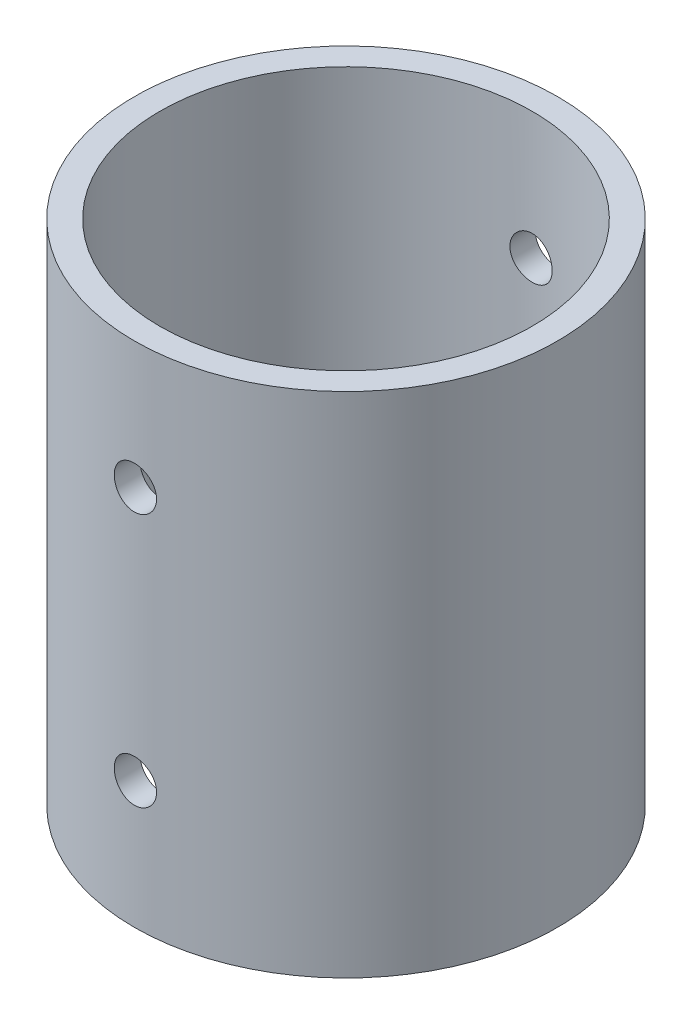
from build123d import *

# Parameters (mm, degrees)
ESBO_O1_R                = 25
ESBO_O1_R_2              = 22
RESSALTO_EXTRUS_O1_DEPTH = 60
ESBO_O2_R                = 2.5
CORTE_EXTRUS_O1_DEPTH    = 70.641941386


with BuildPart() as part:
    # Esboço1 → Ressalto-extrusão1 (new body)
    with BuildSketch(Plane(origin=(0, 0, 0), x_dir=(1, 0, 0), z_dir=(0, 1, 0))):
        with Locations(Location((0, 0, 0), (0, 0, 270))):
            Circle(ESBO_O1_R)
        with Locations(Location((0, 0, 0), (0, 0, 270))):
            Circle(ESBO_O1_R_2, mode=Mode.SUBTRACT)
    extrude(amount=RESSALTO_EXTRUS_O1_DEPTH)

    # Esboço2 → Corte-extrusão1 (cut, symmetric)
    with BuildSketch(Plane.XY):
        with Locations((0, 15)):
            Circle(ESBO_O2_R)
    corte_extrus_o1 = extrude(amount=CORTE_EXTRUS_O1_DEPTH, both=True, mode=Mode.SUBTRACT)

    # Espelhar1: Corte-extrusão1 across plane
    add(corte_extrus_o1.mirror(Plane(origin=(0, 30, 0), x_dir=(0, 0, 1), z_dir=(0, -1, 0))), mode=Mode.SUBTRACT)


solid = part.part
